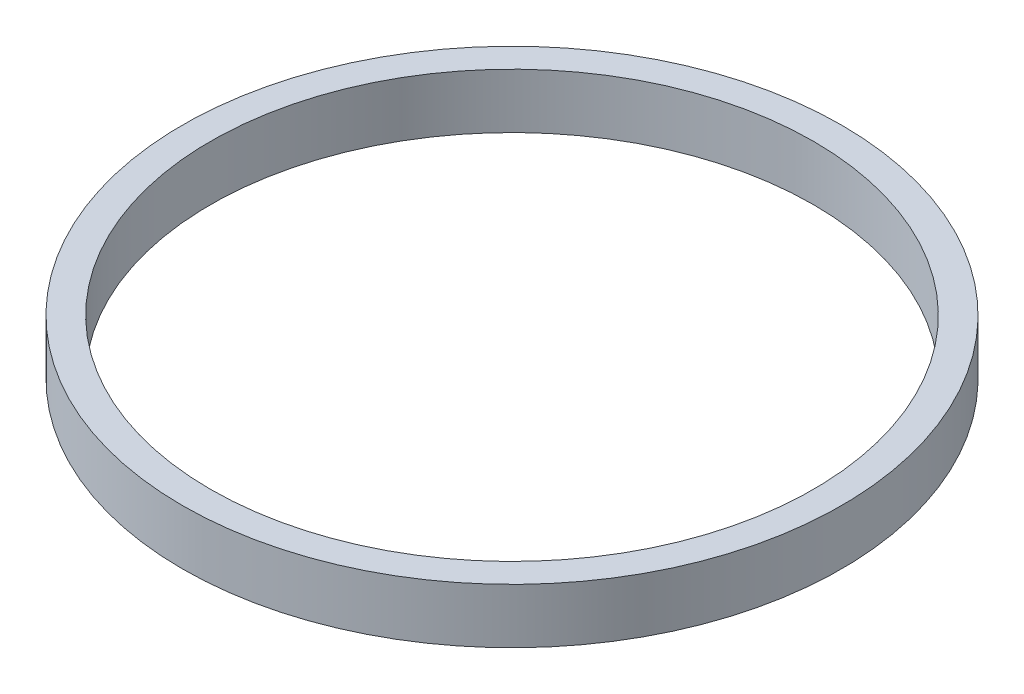
from build123d import *

# Parameters (mm, degrees)
SKETCH1_R           = 76.25
SKETCH1_R_2         = 69.75
BOSS_EXTRUDE1_DEPTH = 12.7


with BuildPart() as part:
    # Sketch1 → Boss-Extrude1 (new body)
    with BuildSketch(Plane(origin=(0, 0, 0), x_dir=(1, 0, 0), z_dir=(0, 1, 0))):
        Circle(SKETCH1_R)
        Circle(SKETCH1_R_2, mode=Mode.SUBTRACT)
    extrude(amount=BOSS_EXTRUDE1_DEPTH)


solid = part.part
